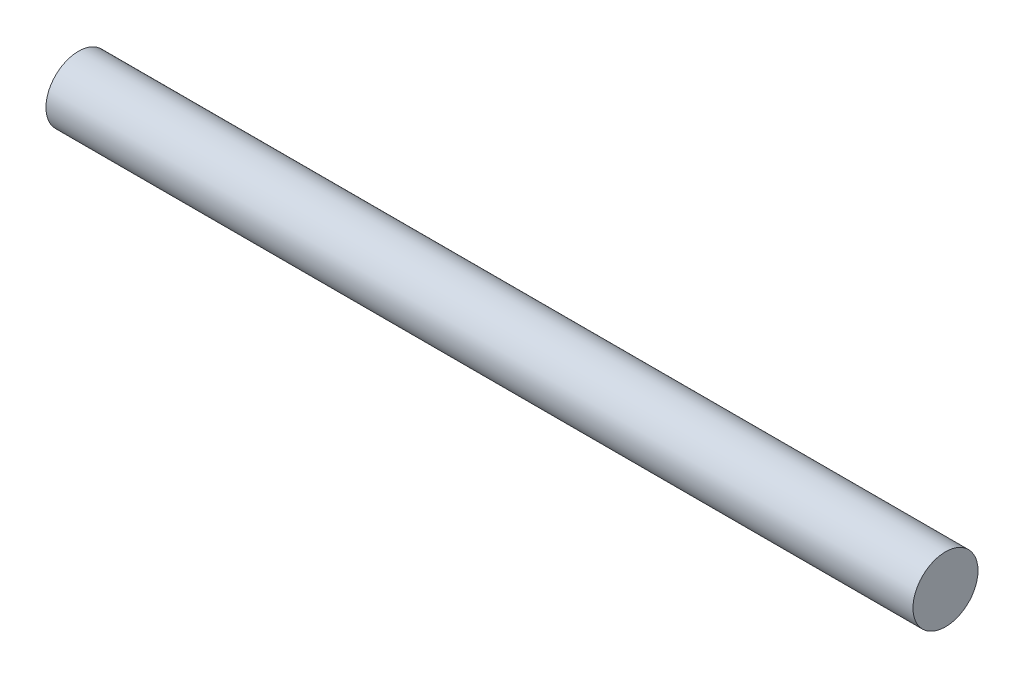
from build123d import *

# Parameters (mm, degrees)
SKETCH1_R           = 0.75
BOSS_EXTRUDE1_DEPTH = 20


with BuildPart() as part:
    # Sketch1 → Boss-Extrude1 (new body)
    with BuildSketch(Plane(origin=(0, 0, 0), x_dir=(0, 0, -1), z_dir=(1, 0, 0))):
        with Locations((-22.694500217, 11.062992171)):
            Circle(SKETCH1_R)
    extrude(amount=BOSS_EXTRUDE1_DEPTH)


solid = part.part
